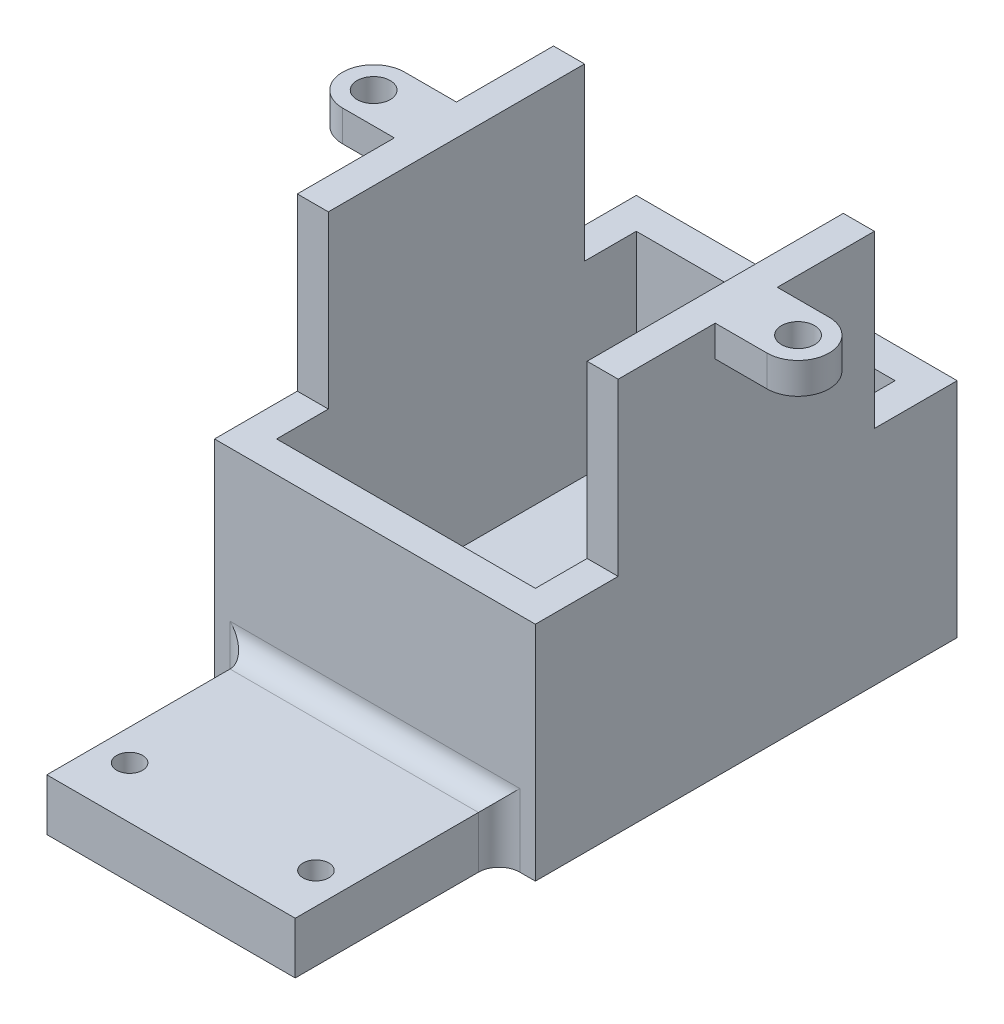
from build123d import *

# Parameters (mm, degrees)
SKETCH_1_W          = 31
SKETCH_1_H          = 38
EXTRUDE_1_DEPTH     = 40.75
SKETCH_2_W          = 8
SKETCH_2_H          = 16.5
CUT_EXTRUDE_1_DEPTH = 40.75
SKETCH_3_W          = 25
SKETCH_3_H          = 34.75
CUT_EXTRUDE_2_DEPTH = 34.5
SKETCH_4_R          = 12.5
CUT_EXTRUDE_3_DEPTH = 34.5
SKETCH_5_R          = 1.6
EXTRUDE_2_DEPTH     = 3
SKETCH_6_W          = 31
SKETCH_6_H          = 16.5
CUT_EXTRUDE_4_DEPTH = 8
SKETCH_7_W          = 24
SKETCH_7_H          = 5
EXTRUDE_3_DEPTH     = 19.7
SKETCH_8_R          = 1.25
CUT_EXTRUDE_5_DEPTH = 20.7
FILLET_1_R          = 2


with BuildPart() as part:
    # 草图1 → 凸台-拉伸1 (new body)
    with BuildSketch(Plane.XY):
        with Locations((15.5, 19)):
            Rectangle(SKETCH_1_W, SKETCH_1_H)
    extrude(amount=-EXTRUDE_1_DEPTH)

    # 草图2 → 切除-拉伸1 (cut)
    with BuildSketch(Plane(origin=(31, 0, 0), x_dir=(0, 0, -1), z_dir=(1, 0, 0))):
        with Locations((36.75, 29.75)):
            Rectangle(SKETCH_2_W, SKETCH_2_H)
    extrude(amount=-CUT_EXTRUDE_1_DEPTH, mode=Mode.SUBTRACT)

    # 草图3 → 切除-拉伸2 (cut)
    with BuildSketch(Plane(origin=(0, 38, 0), x_dir=(1, 0, 0), z_dir=(0, 1, 0))):
        with Locations((15.5, 20.375)):
            Rectangle(SKETCH_3_W, SKETCH_3_H)
    extrude(amount=-CUT_EXTRUDE_2_DEPTH, mode=Mode.SUBTRACT)

    # 草图4 → 切除-拉伸3 (cut)
    with BuildSketch(Plane.XY):
        with Locations((15.5, 38)):
            Circle(SKETCH_4_R)
    extrude(amount=-CUT_EXTRUDE_3_DEPTH, mode=Mode.SUBTRACT)

    # 草图5 → 凸台-拉伸2 (add)
    with BuildSketch(Plane(origin=(0, 38, 0), x_dir=(1, 0, 0), z_dir=(0, 1, 0))):
        with BuildLine():
            Line((36, 23.375), (31, 23.375))
            Line((31, 23.375), (31, 17.375))
            Line((31, 17.375), (36, 17.375))
            ThreePointArc((36, 17.375), (39, 20.375), (36, 23.375))
        make_face()
        with Locations((36, 20.375)):
            Circle(SKETCH_5_R, mode=Mode.SUBTRACT)
        with BuildLine():
            Line((0, 23.375), (0, 17.375))
            Line((0, 17.375), (-5, 17.375))
            ThreePointArc((-5, 17.375), (-8, 20.375), (-5, 23.375))
            Line((-5, 23.375), (0, 23.375))
        make_face()
        with Locations((-5, 20.375)):
            Circle(SKETCH_5_R, mode=Mode.SUBTRACT)
    extrude(amount=-EXTRUDE_2_DEPTH)

    # 草图6 → 切除-拉伸4 (cut)
    with BuildSketch(Plane.XY):
        with Locations((15.5, 29.75)):
            Rectangle(SKETCH_6_W, SKETCH_6_H)
    extrude(amount=-CUT_EXTRUDE_4_DEPTH, mode=Mode.SUBTRACT)

    # 草图7 → 凸台-拉伸3 (add)
    with BuildSketch(Plane.XY):
        with Locations((15.5, 2.5)):
            Rectangle(SKETCH_7_W, SKETCH_7_H)
    extrude(amount=EXTRUDE_3_DEPTH)

    # 草图8 → 切除-拉伸5 (cut)
    with BuildSketch(Plane(origin=(0, 5, 0), x_dir=(1, 0, 0), z_dir=(0, 1, 0))):
        with Locations((6.5, -14.7)):
            Circle(SKETCH_8_R)
        with Locations((24.5, -14.7)):
            Circle(SKETCH_8_R)
    extrude(amount=-CUT_EXTRUDE_5_DEPTH, mode=Mode.SUBTRACT)

    # 圆角1
    fillet_1_edges = [part.edges().sort_by_distance(p)[0] for p in [
        (3.5, 2.5, 0),
        (27.5, 2.5, 0),
        (15.5, 5, 0),
    ]]
    fillet(fillet_1_edges, radius=FILLET_1_R)


solid = part.part
